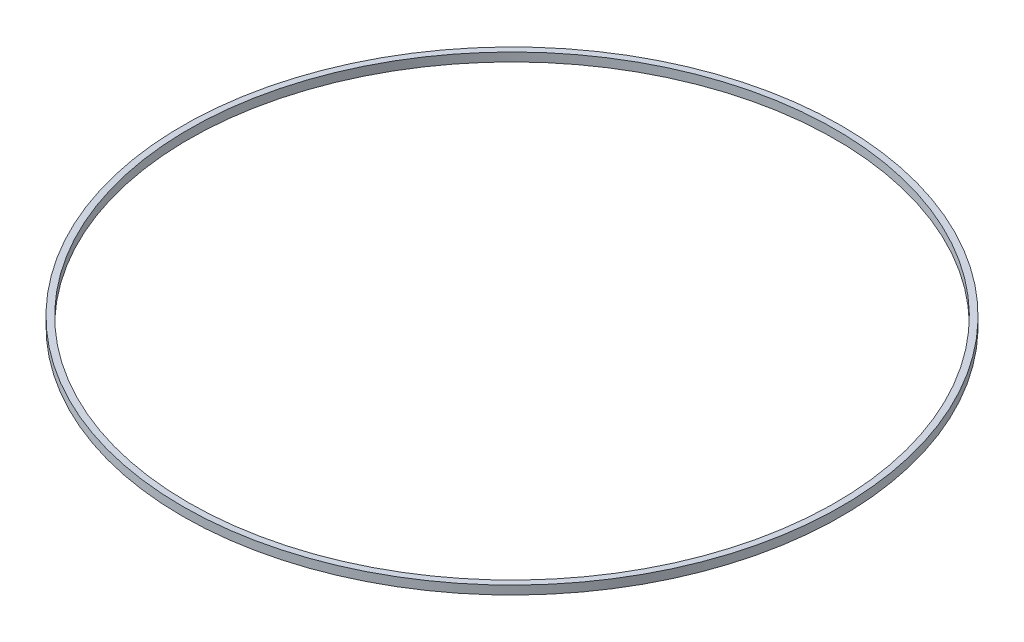
from build123d import *

# Parameters (mm, degrees)
SKETCH1_R           = 53.52
SKETCH1_R_2         = 52.52
BOSS_EXTRUDE1_DEPTH = 1.4


with BuildPart() as part:
    # Sketch1 → Boss-Extrude1 (new body)
    with BuildSketch(Plane(origin=(0, 0, 0), x_dir=(1, 0, 0), z_dir=(0, 1, 0))):
        Circle(SKETCH1_R)
        Circle(SKETCH1_R_2, mode=Mode.SUBTRACT)
    extrude(amount=BOSS_EXTRUDE1_DEPTH)


solid = part.part
